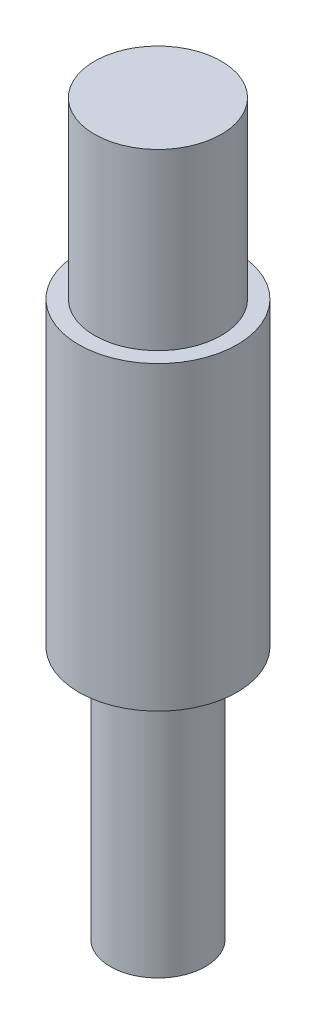
from build123d import *


with BuildPart() as part:
    # 草图1 → 旋转1 (revolve)
    with BuildSketch(Plane.XY):
        Polygon((0, 0), (2, 0), (2, -5.5), (2.5, -5.5), (2.5, -15), (1.5, -15), (1.5, -23), (0, -23), align=None)
    revolve(axis=Axis((0, 9.186035128, 0), (0, -1, 0)))


solid = part.part
